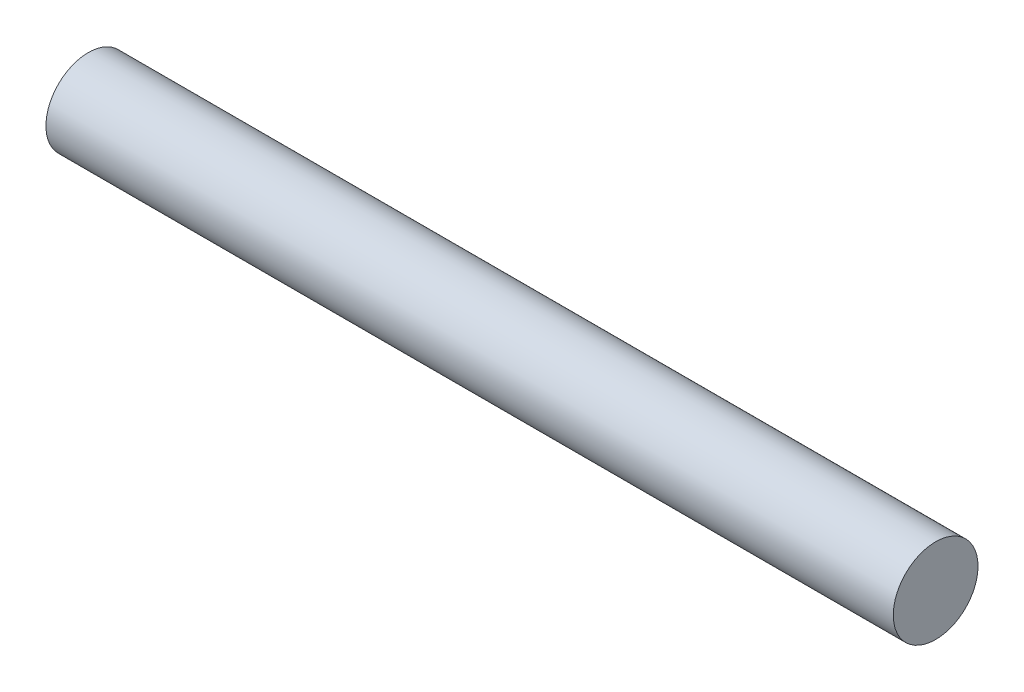
from build123d import *

# Parameters (mm, degrees)
SKETCH1_R           = 15.24
BOSS_EXTRUDE1_DEPTH = 304.8


with BuildPart() as part:
    # Sketch1 → Boss-Extrude1 (new body)
    with BuildSketch(Plane(origin=(0, 0, 0), x_dir=(0, 0, -1), z_dir=(1, 0, 0))):
        Circle(SKETCH1_R)
    extrude(amount=BOSS_EXTRUDE1_DEPTH)


solid = part.part
